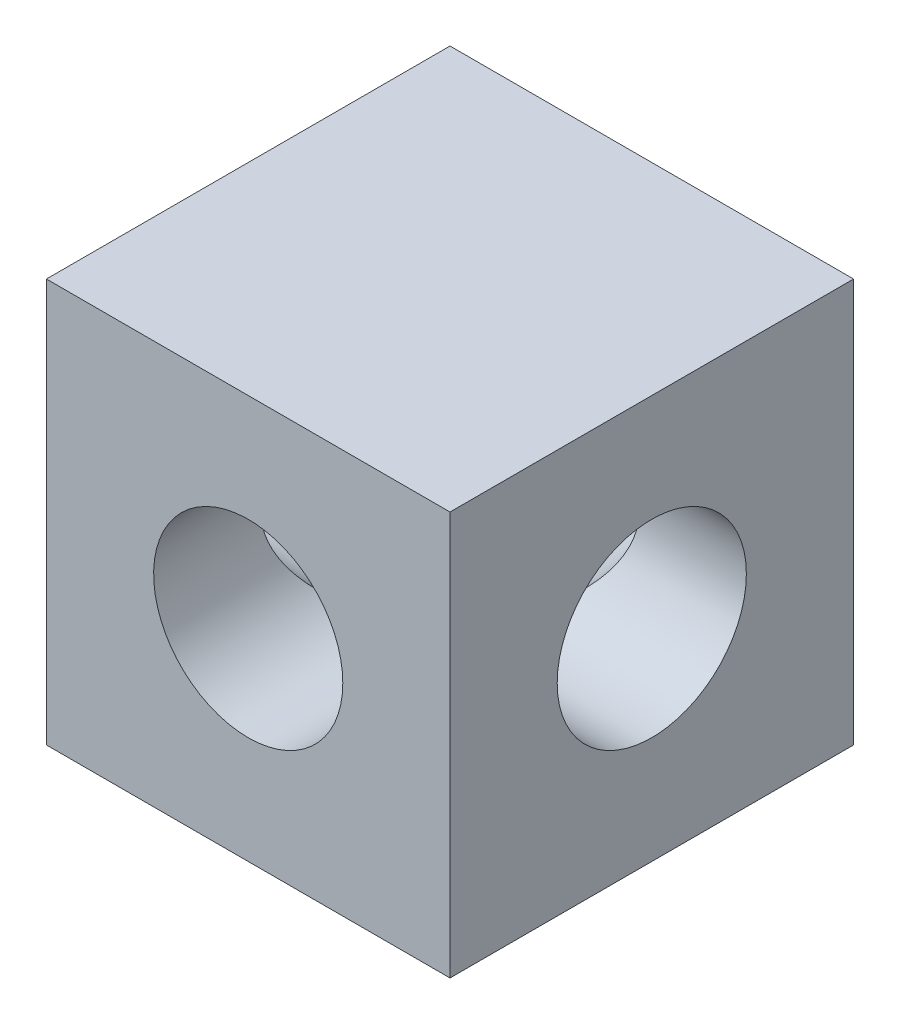
from build123d import *

# Parameters (mm, degrees)
SKETCH1_W           = 20.32
SKETCH1_H           = 20.32
SKETCH1_R           = 4.7625
BOSS_EXTRUDE1_DEPTH = 10.16
SKETCH2_R           = 4.7625
CUT_EXTRUDE1_DEPTH  = 21.32


with BuildPart() as part:
    # Sketch1 → Boss-Extrude1 (new body, symmetric)
    with BuildSketch(Plane.XY):
        Rectangle(SKETCH1_W, SKETCH1_H)
        Circle(SKETCH1_R, mode=Mode.SUBTRACT)
    extrude(amount=BOSS_EXTRUDE1_DEPTH, both=True)

    # Sketch2 → Cut-Extrude1 (cut, through all)
    with BuildSketch(Plane(origin=(10.16, 0, 0), x_dir=(0, 0, -1), z_dir=(1, 0, 0))):
        Circle(SKETCH2_R)
    extrude(amount=-CUT_EXTRUDE1_DEPTH, mode=Mode.SUBTRACT)


solid = part.part
